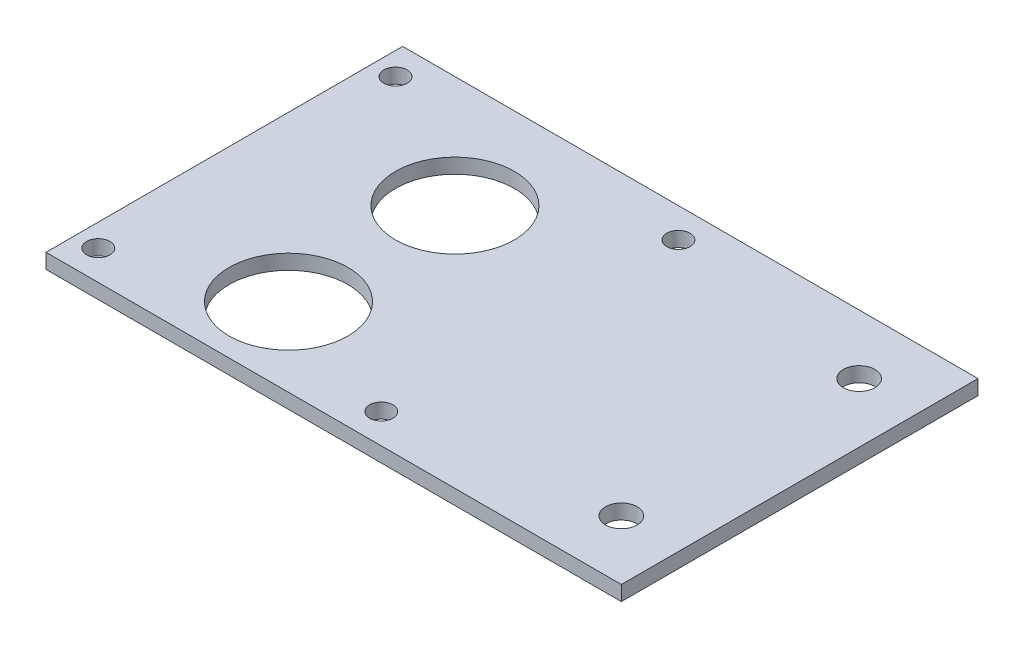
from build123d import *

# Parameters (mm, degrees)
SKETCH2_W                    = 122.936
SKETCH2_H                    = 76.2
BOSS_EXTRUDE1_DEPTH          = 3.175
F_10_0_1935_DIAMETER_HOLE1_D = 4.9784
LPATTERN1_COUNT              = 2
LPATTERN1_PITCH              = 60.452
F_1_4_0_25_DIAMETER_HOLE1_D  = 6.7564
MIRROR1_COPY_1_D             = 4.9784
SKETCH7_R                    = 12.7
CUT_EXTRUDE1_DEPTH           = 4.175


with BuildPart() as part:
    # Sketch2 → Boss-Extrude1 (new body)
    with BuildSketch(Plane(origin=(0, 0, 0), x_dir=(1, 0, 0), z_dir=(0, 1, 0))):
        with Locations((61.468, 38.1)):
            Rectangle(SKETCH2_W, SKETCH2_H)
    extrude(amount=BOSS_EXTRUDE1_DEPTH)

    # #10 (0.1935) Diameter Hole1 (through all)
    with Locations(Plane(origin=(0, 3.175, 0), x_dir=(1, 0, 0), z_dir=(0, 1, 0))):
        with Locations((4.826, 69.85)):
            f_10_0_1935_diameter_hole1 = Hole(F_10_0_1935_DIAMETER_HOLE1_D / 2)

    # LPattern1: #10 (0.1935) Diameter Hole1 ×2
    with Locations(*[(i * LPATTERN1_PITCH, 0, 0) for i in range(1, LPATTERN1_COUNT)]):
        add(f_10_0_1935_diameter_hole1, mode=Mode.SUBTRACT)

    # 1/4 (0.25) Diameter Hole1 (through all)
    with Locations(Plane(origin=(0, 3.175, 0), x_dir=(1, 0, 0), z_dir=(0, 1, 0))):
        with Locations((110.236, 63.5)):
            f_1_4_0_25_diameter_hole1 = Hole(F_1_4_0_25_DIAMETER_HOLE1_D / 2)

    # Mirror1: 1/4 (0.25) Diameter Hole1, #10 (0.1935) Diameter Hole1 across plane
    add(f_1_4_0_25_diameter_hole1.mirror(Plane(origin=(0, 0, -38.1), x_dir=(1, 0, 0), z_dir=(0, 0, -1))), mode=Mode.SUBTRACT)
    add(f_10_0_1935_diameter_hole1.mirror(Plane(origin=(0, 0, -38.1), x_dir=(1, 0, 0), z_dir=(0, 0, -1))), mode=Mode.SUBTRACT)

    # Mirror1 copy 1 (through all)
    with Locations(Plane(origin=(60.452, 3.175, -76.2), x_dir=(1, 0, 0), z_dir=(0, 1, 0))):
        with Locations((4.826, -69.85)):
            Hole(MIRROR1_COPY_1_D / 2)

    # Sketch7 → Cut-Extrude1 (cut, through all)
    with BuildSketch(Plane(origin=(0, 3.175, 0), x_dir=(1, 0, 0), z_dir=(0, 1, 0))):
        with Locations((35.052, 16.764)):
            Circle(SKETCH7_R)
        with Locations((35.052, 52.324)):
            Circle(SKETCH7_R)
    extrude(amount=-CUT_EXTRUDE1_DEPTH, mode=Mode.SUBTRACT)


solid = part.part
